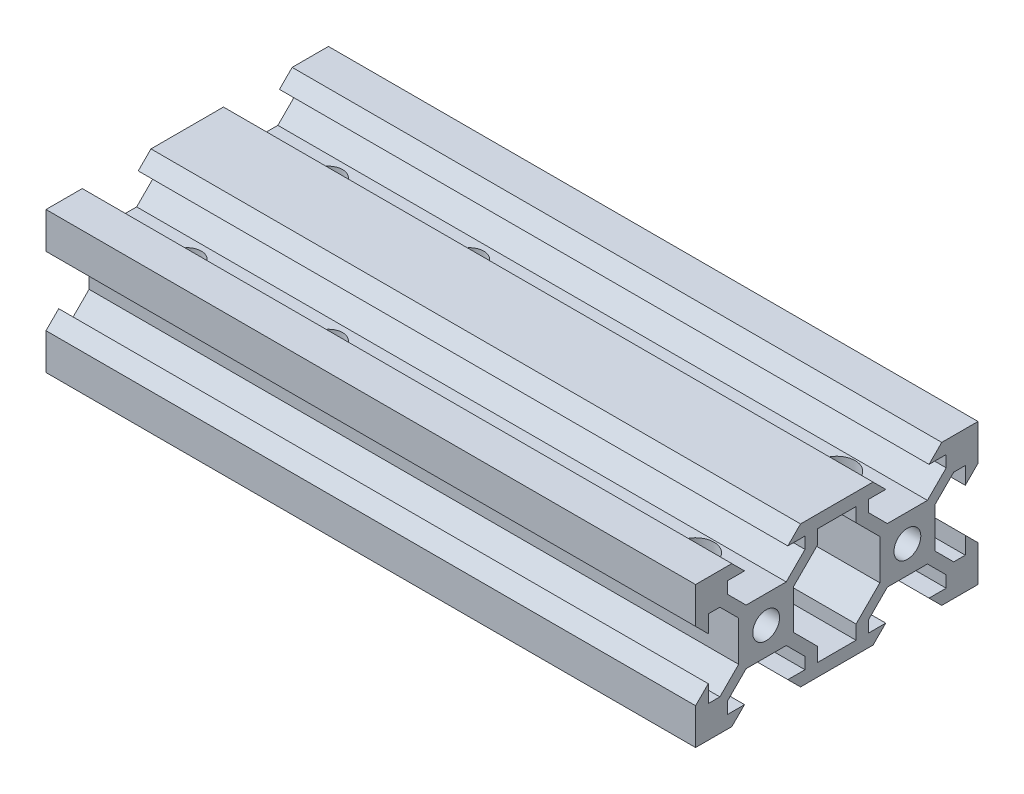
from build123d import *

# Parameters (mm, degrees)
SKETCH1_W           = 92
SKETCH1_H           = 40
BOSS_EXTRUDE1_DEPTH = 20
SKETCH7_R           = 1.9
CUT_EXTRUDE13_DEPTH = 93
SKETCH16_R          = 2.6
CUT_EXTRUDE11_DEPTH = 14.9
SKETCH17_R          = 2
CUT_EXTRUDE14_DEPTH = 14.9


with BuildPart() as part:
    # Sketch1 → Boss-Extrude1 (new body)
    with BuildSketch(Plane(origin=(0, 0, 0), x_dir=(1, 0, 0), z_dir=(0, 1, 0))):
        Rectangle(SKETCH1_W, SKETCH1_H)
    extrude(amount=BOSS_EXTRUDE1_DEPTH)

    # Sketch7 → Cut-Extrude13 (cut, through all)
    with BuildSketch(Plane(origin=(46, 0, 0), x_dir=(0, 0, -1), z_dir=(1, 0, 0))):
        Polygon((-12.839339828, 13.9), (-7.159339828, 13.9), (-4.499339828, 16.56), (-4.499339828, 18.2), (-6.934339828, 18.2), (-5.134339828, 20), (-14.864339828, 20), (-13.064339828, 18.2), (-15.499339828, 18.2), (-15.499339828, 16.56), align=None)
        Polygon((-18.2, 13.064339828), (-20, 14.864339828), (-20, 5.134339828), (-18.2, 6.934339828), (-18.2, 4.499339828), (-16.56, 4.499339828), (-13.9, 7.159339828), (-13.9, 12.839339828), (-16.56, 15.499339828), (-18.2, 15.499339828), align=None)
        Polygon((-13.064339828, 1.798679656), (-14.863019485, 0), (-5.135660172, 0), (-6.934339828, 1.798679656), (-4.499339828, 1.798679656), (-4.499339828, 3.438679656), (-7.159339828, 6.098679656), (-12.839339828, 6.098679656), (-15.499339828, 3.438679656), (-15.499339828, 1.798679656), align=None)
        Polygon((6.098679656, 12.839339828), (6.098679656, 7.159339828), (2.73, 3.790660172), (2.73, 1.798679656), (-2.73, 1.798679656), (-2.73, 3.790660172), (-6.098679656, 7.159339828), (-6.098679656, 12.839339828), (-2.73, 16.208019485), (-2.73, 18.2), (2.73, 18.2), (2.73, 16.208019485), align=None)
        Polygon((5.135660172, 0), (14.863019485, 0), (13.064339828, 1.798679656), (15.499339828, 1.798679656), (15.499339828, 3.438679656), (12.839339828, 6.098679656), (7.159339828, 6.098679656), (4.499339828, 3.438679656), (4.499339828, 1.798679656), (6.934339828, 1.798679656), align=None)
        Polygon((20, 5.134339828), (20, 14.864339828), (18.2, 13.064339828), (18.2, 15.499339828), (16.56, 15.499339828), (13.9, 12.839339828), (13.9, 7.159339828), (16.56, 4.499339828), (18.2, 4.499339828), (18.2, 6.934339828), align=None)
        Polygon((14.864339828, 20), (5.134339828, 20), (6.934339828, 18.2), (4.499339828, 18.2), (4.499339828, 16.56), (7.159339828, 13.9), (12.839339828, 13.9), (15.499339828, 16.56), (15.499339828, 18.2), (13.064339828, 18.2), align=None)
        with Locations((-10, 10)):
            Circle(SKETCH7_R)
        with Locations((10, 10)):
            Circle(SKETCH7_R)
    extrude(amount=-CUT_EXTRUDE13_DEPTH, mode=Mode.SUBTRACT)

    # Sketch16 → Cut-Extrude11 (cut, through all)
    with BuildSketch(Plane(origin=(0, 13.9, 0), x_dir=(1, 0, 0), z_dir=(0, 1, 0))):
        with Locations((36, -9.999339828)):
            Circle(SKETCH16_R)
        with Locations((36, 9.999339828)):
            Circle(SKETCH16_R)
    extrude(amount=-CUT_EXTRUDE11_DEPTH, mode=Mode.SUBTRACT)

    # Sketch17 → Cut-Extrude14 (cut, through all)
    with BuildSketch(Plane(origin=(0, 13.9, 0), x_dir=(1, 0, 0), z_dir=(0, 1, 0))):
        with Locations((-36, -9.999339828)):
            Circle(SKETCH17_R)
        with Locations((-16, -9.999339828)):
            Circle(SKETCH17_R)
        with Locations((-36, 9.999339828)):
            Circle(SKETCH17_R)
        with Locations((-16, 9.999339828)):
            Circle(SKETCH17_R)
    extrude(amount=-CUT_EXTRUDE14_DEPTH, mode=Mode.SUBTRACT)


solid = part.part
